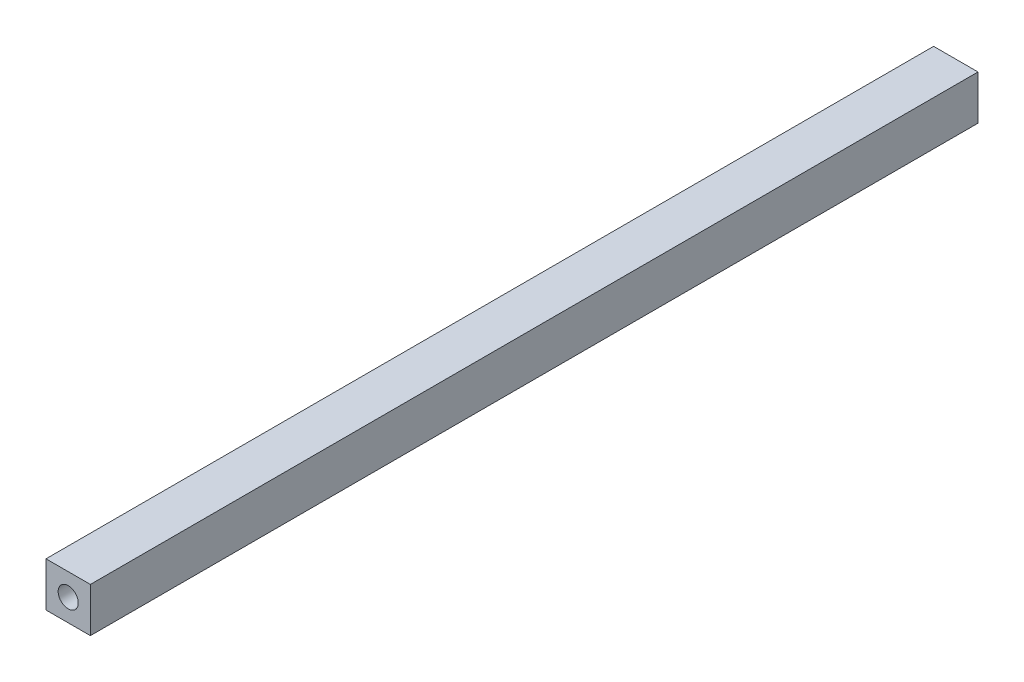
from build123d import *

# Parameters (mm, degrees)
IZIM1_W                     = 15
IZIM1_H                     = 15
Y_KSEKLIK_EKSTR_ZYON1_DEPTH = 150


with BuildPart() as part:
    # Çizim1 → Yükseklik-Ekstrüzyon1 (new body, symmetric)
    with BuildSketch(Plane.XY):
        Rectangle(IZIM1_W, IZIM1_H)
    extrude(amount=Y_KSEKLIK_EKSTR_ZYON1_DEPTH, both=True)

    # Çizim3 → M8 Dişli Delik1 (revolve, cut)
    with BuildSketch(Plane(origin=(0, 0, 150), x_dir=(0, -1, 0), z_dir=(1, 0, 0))):
        Polygon((0, 0), (0, 24.292926105), (3.4, 22.25), (3.4, 0), align=None)
    m8_di_li_delik1 = revolve(axis=Axis((0, 0, 156.35), (0, 0, -1)), mode=Mode.SUBTRACT)

    # Aynalama1: M8 Dişli Delik1 across plane
    add(m8_di_li_delik1.mirror(Plane.XY), mode=Mode.SUBTRACT)


solid = part.part
